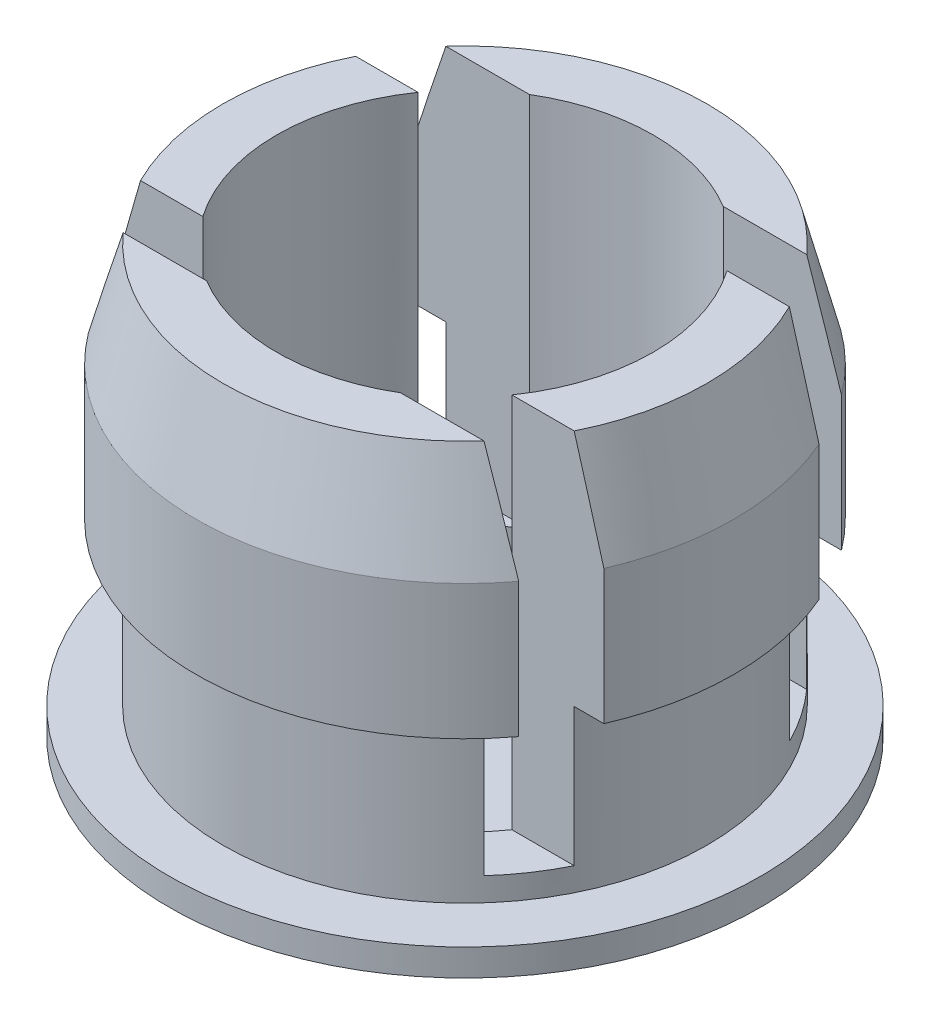
from build123d import *

# Parameters (mm, degrees)
CROQUIS2_W            = 26
CROQUIS2_H            = 2
CORTAR_EXTRUIR1_DEPTH = 14


with BuildPart() as part:
    # Croquis1 → Revolución1 (revolve)
    with BuildSketch(Plane.XY):
        Polygon((-89.778094977, -14.637996222), (-78.782252338, -14.637996222), (-78.782252338, -13.637996222), (-85.782252338, -13.637996222), (-85.782252338, 1.235955759), (-87.782252338, 1.235955759), (-88.782252338, -2.637996222), (-88.782252338, -7.637996222), (-87.782252338, -7.637996222), (-87.782252338, -13.637996222), (-89.778094977, -13.637996222), align=None)
    revolve(axis=Axis((-78.782252338, -14.637996222, 0), (0, 1, 0)))

    # Croquis2 → Cortar-Extruir1 (cut)
    with BuildSketch(Plane(origin=(0, 1.235955759, 0), x_dir=(1, 0, 0), z_dir=(0, 1, 0))):
        with Locations((-78.782252338, -5)):
            Rectangle(CROQUIS2_W, CROQUIS2_H)
        with Locations((-78.782252338, 5)):
            Rectangle(CROQUIS2_W, CROQUIS2_H)
    extrude(amount=-CORTAR_EXTRUIR1_DEPTH, mode=Mode.SUBTRACT)


solid = part.part
